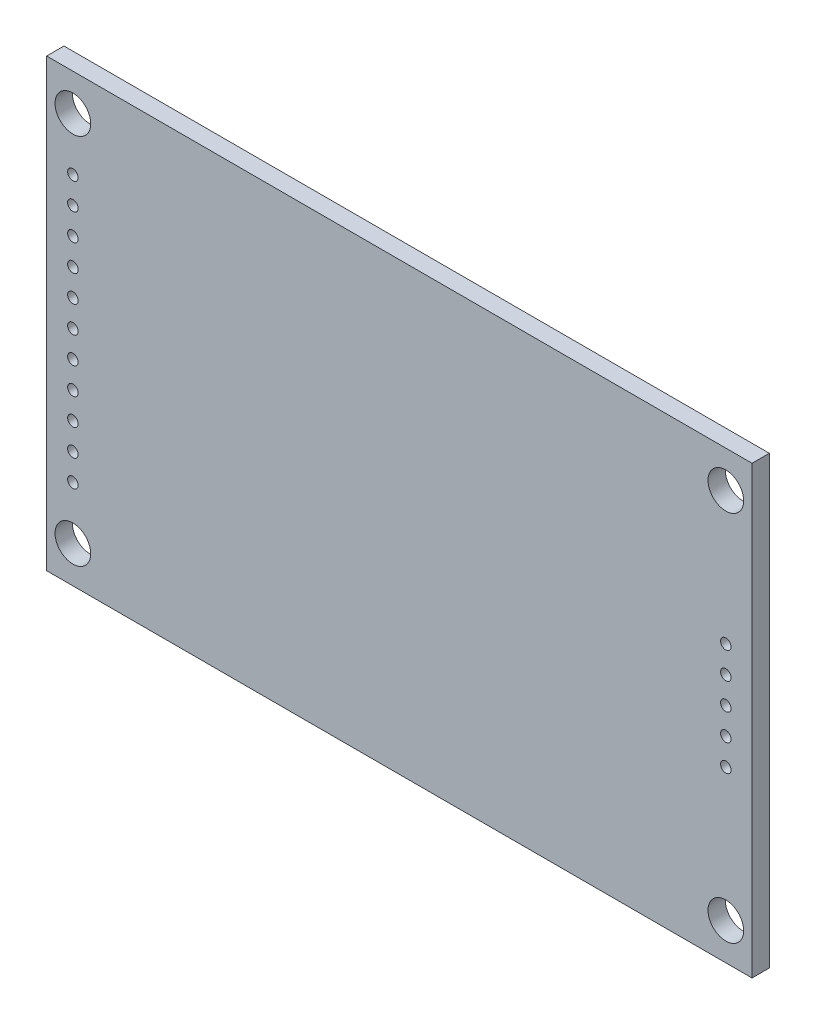
from build123d import *

# Parameters (mm, degrees)
SKETCH2_W           = 67.25
SKETCH2_H           = 42.5
BOSS_EXTRUDE1_DEPTH = 1.65
SKETCH3_R           = 1.7
CUT_EXTRUDE1_DEPTH  = 1.65
SKETCH5_R           = 0.5
CUT_EXTRUDE2_DEPTH  = 1.65
SKETCH8_R           = 0.5
CUT_EXTRUDE3_DEPTH  = 1.65


with BuildPart() as part:
    # Sketch2 → Boss-Extrude1 (new body)
    with BuildSketch(Plane.XY):
        Rectangle(SKETCH2_W, SKETCH2_H)
    extrude(amount=BOSS_EXTRUDE1_DEPTH)

    # Sketch3 → Cut-Extrude1 (cut)
    with BuildSketch(Plane(origin=(0, 0, 0), x_dir=(-1, 0, 0), z_dir=(0, 0, -1))):
        with Locations((31.125, -17.75)):
            Circle(SKETCH3_R)
        with Locations((31.125, 17.75)):
            Circle(SKETCH3_R)
        with Locations((-31.125, -17.75)):
            Circle(SKETCH3_R)
        with Locations((-31.125, 17.75)):
            Circle(SKETCH3_R)
    extrude(amount=-CUT_EXTRUDE1_DEPTH, mode=Mode.SUBTRACT)

    # Sketch5 → Cut-Extrude2 (cut)
    with BuildSketch(Plane.XY.offset(1.65)):
        with Locations((-31.125, 0)):
            Circle(SKETCH5_R)
        with Locations((-31.125, -2.54)):
            Circle(SKETCH5_R)
        with Locations((-31.125, -5.08)):
            Circle(SKETCH5_R)
        with Locations((-31.125, -7.62)):
            Circle(SKETCH5_R)
        with Locations((-31.125, -10.16)):
            Circle(SKETCH5_R)
        with Locations((-31.125, -12.7)):
            Circle(SKETCH5_R)
        with Locations((-31.125, 2.54)):
            Circle(SKETCH5_R)
        with Locations((-31.125, 5.08)):
            Circle(SKETCH5_R)
        with Locations((-31.125, 7.62)):
            Circle(SKETCH5_R)
        with Locations((-31.125, 10.16)):
            Circle(SKETCH5_R)
        with Locations((-31.125, 12.7)):
            Circle(SKETCH5_R)
    extrude(amount=-CUT_EXTRUDE2_DEPTH, mode=Mode.SUBTRACT)

    # Sketch8 → Cut-Extrude3 (cut)
    with BuildSketch(Plane.XY.offset(1.65)):
        with Locations((31.125, 0)):
            Circle(SKETCH8_R)
        with Locations((31.125, 2.54)):
            Circle(SKETCH8_R)
        with Locations((31.125, 5.08)):
            Circle(SKETCH8_R)
        with Locations((31.125, -2.54)):
            Circle(SKETCH8_R)
        with Locations((31.125, -5.08)):
            Circle(SKETCH8_R)
    extrude(amount=-CUT_EXTRUDE3_DEPTH, mode=Mode.SUBTRACT)


solid = part.part
